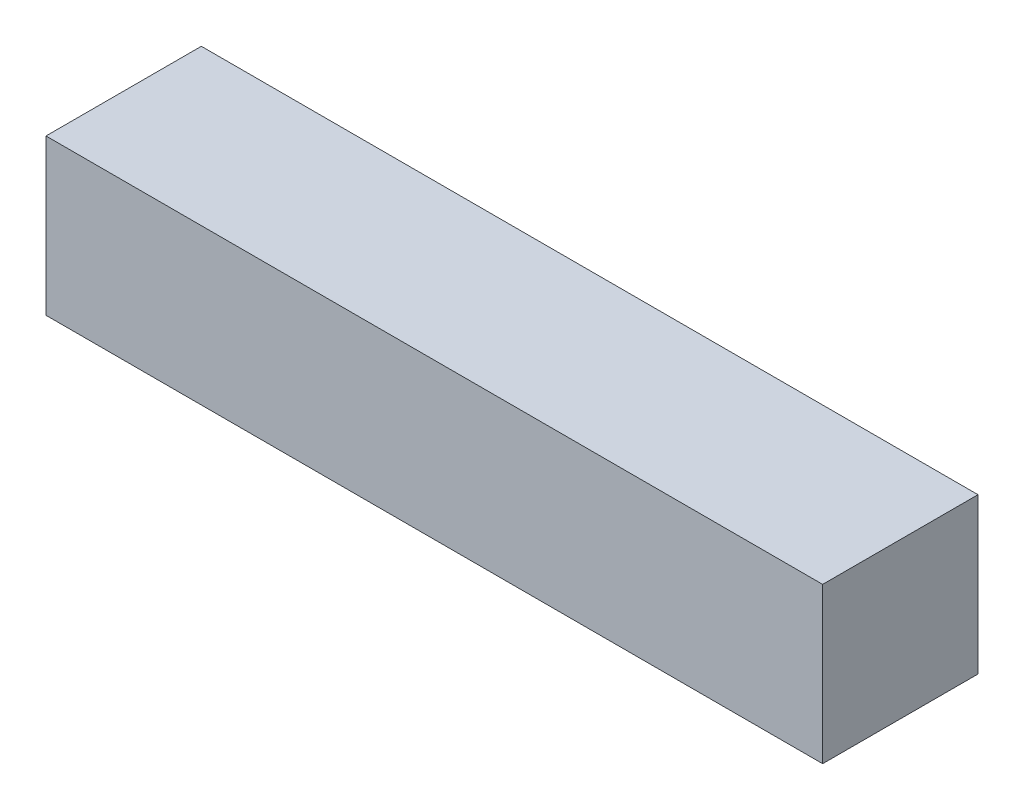
from build123d import *

# Parameters (mm, degrees)
SKETCH1_W           = 25.4
SKETCH1_H           = 25.4
BOSS_EXTRUDE1_DEPTH = 127


with BuildPart() as part:
    # Sketch1 → Boss-Extrude1 (new body)
    with BuildSketch(Plane(origin=(0, 0, 0), x_dir=(0, 0, -1), z_dir=(1, 0, 0))):
        Rectangle(SKETCH1_W, SKETCH1_H)
    extrude(amount=BOSS_EXTRUDE1_DEPTH)


solid = part.part
